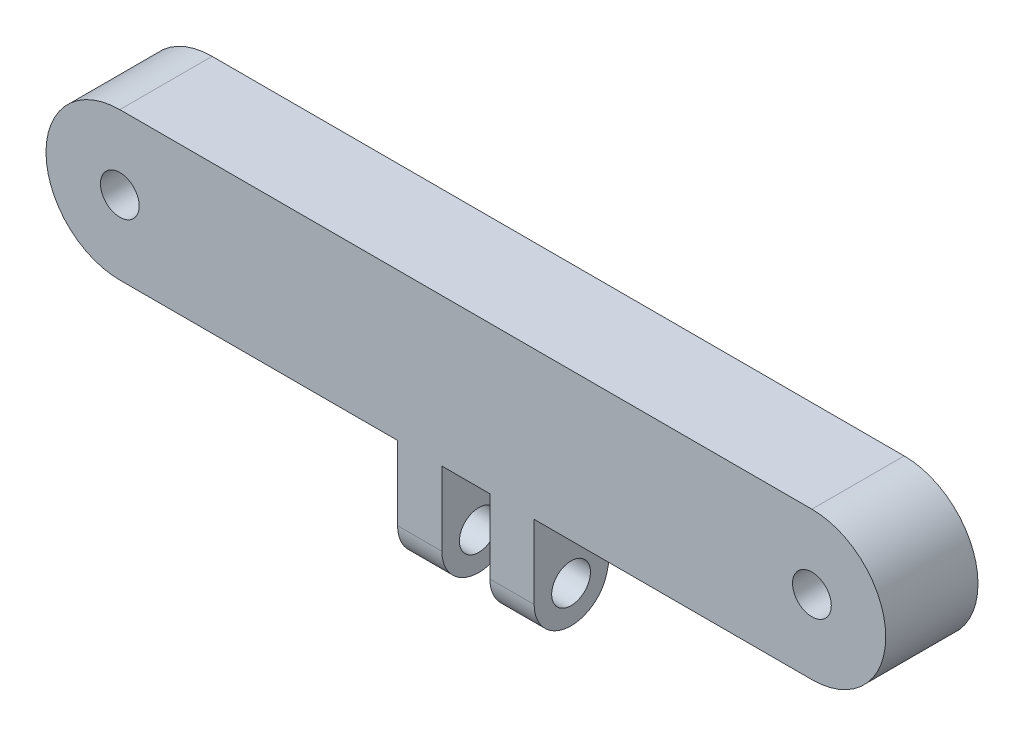
from build123d import *

# Parameters (mm, degrees)
SKETCH1_R               = 2.1
BOSS_EXTRUDE1_DEPTH     = 10
SHELL2_T                = -3
SKETCH2_R               = 2.1
BOSS_EXTRUDE2_DEPTH     = 7.4
SKETCH3_W               = 5.2
SKETCH3_H               = 14
CUT_EXTRUDE1_DEPTH      = 1
CUT_EXTRUDE1_DEPTH_BACK = 11


with BuildPart() as part:
    # Sketch1 → Boss-Extrude1 (new body)
    with BuildSketch(Plane.XY):
        with BuildLine():
            Line((-37.5, 8), (37.5, 8))
            ThreePointArc((37.5, 8), (45.5, 0), (37.5, -8))
            Line((37.5, -8), (-37.5, -8))
            ThreePointArc((-37.5, -8), (-45.5, 0), (-37.5, 8))
        make_face()
        with Locations((-37.5, 0)):
            Circle(SKETCH1_R, mode=Mode.SUBTRACT)
        with Locations((37.5, 0)):
            Circle(SKETCH1_R, mode=Mode.SUBTRACT)
    extrude(amount=BOSS_EXTRUDE1_DEPTH)

    # Shell2
    shell2_openings = [part.faces().sort_by_distance(p)[0] for p in [
        (0, 0, 0),
    ]]
    offset(amount=SHELL2_T, openings=shell2_openings, kind=Kind.INTERSECTION)

    # Sketch2 → Boss-Extrude2 (add, symmetric)
    with BuildSketch(Plane(origin=(0, 0, 0), x_dir=(0, 0, -1), z_dir=(1, 0, 0))):
        with BuildLine():
            Line((-10, -8), (-10, -16))
            ThreePointArc((-10, -16), (-6.46292884, -19.973121807), (-2.107151555, -16.919636334))
            Line((-2.107151555, -16.919636334), (0, -8))
            Line((0, -8), (-10, -8))
        make_face()
        with Locations((-6, -16)):
            Circle(SKETCH2_R, mode=Mode.SUBTRACT)
    extrude(amount=BOSS_EXTRUDE2_DEPTH, both=True)

    # Sketch3 → Cut-Extrude1 (cut, two sides)
    with BuildSketch(Plane.XY.offset(10)) as cut_extrude1_sk:
        with Locations((0, -15)):
            Rectangle(SKETCH3_W, SKETCH3_H)
    extrude(amount=CUT_EXTRUDE1_DEPTH, mode=Mode.SUBTRACT)
    extrude(cut_extrude1_sk.sketch, amount=-CUT_EXTRUDE1_DEPTH_BACK, mode=Mode.SUBTRACT)


solid = part.part
